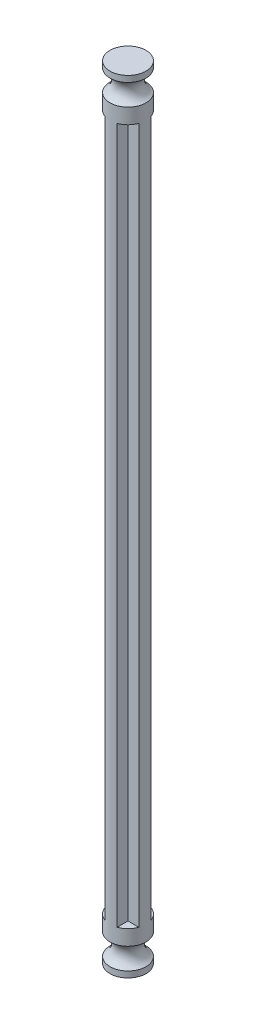
from build123d import *

# Parameters (mm, degrees)
EXTRUDE_2_DEPTH = 114


with BuildPart() as part:
    # 草图1 → 凸台-拉伸2 (new body)
    with BuildSketch(Plane(origin=(0, 0, 0), x_dir=(1, 0, 0), z_dir=(0, 1, 0))):
        with BuildLine():
            Line((1, 1), (1, 2.775338))
            ThreePointArc((1, 2.775338), (0, 2.95), (-1, 2.775338))
            Line((-1, 2.775338), (-1, 1))
            Line((-1, 1), (-2.775338, 1))
            ThreePointArc((-2.775338, 1), (-2.95, 0), (-2.775338, -1))
            Line((-2.775338, -1), (-1, -1))
            Line((-1, -1), (-1, -2.775338))
            ThreePointArc((-1, -2.775338), (0, -2.95), (1, -2.775338))
            Line((1, -2.775338), (1, -1))
            Line((1, -1), (2.775338, -1))
            ThreePointArc((2.775338, -1), (2.95, 0), (2.775338, 1))
            Line((2.775338, 1), (1, 1))
        make_face()
    extrude(amount=EXTRUDE_2_DEPTH)

    # 草图3 → 旋转3 (revolve)
    with BuildSketch(Plane(origin=(0, 0, 0), x_dir=(0, 0, -1), z_dir=(1, 0, 0))):
        with BuildLine():
            Line((0, 114), (0, 121))
            Line((0, 121), (2.95, 121))
            Line((2.95, 121), (2.95, 120))
            ThreePointArc((2.95, 120), (1.918246, 118.25), (2.95, 116.5))
            Line((2.95, 116.5), (2.95, 114))
            Line((2.95, 114), (0, 114))
        make_face()
        with BuildLine():
            Line((0, 0), (0, -7))
            Line((0, -7), (2.95, -7))
            Line((2.95, -7), (2.95, -6))
            ThreePointArc((2.95, -6), (1.918246, -4.25), (2.95, -2.5))
            Line((2.95, -2.5), (2.95, 0))
            Line((2.95, 0), (0, 0))
        make_face()
    revolve(axis=Axis((0, 0, 0), (0, -1, 0)))


solid = part.part
